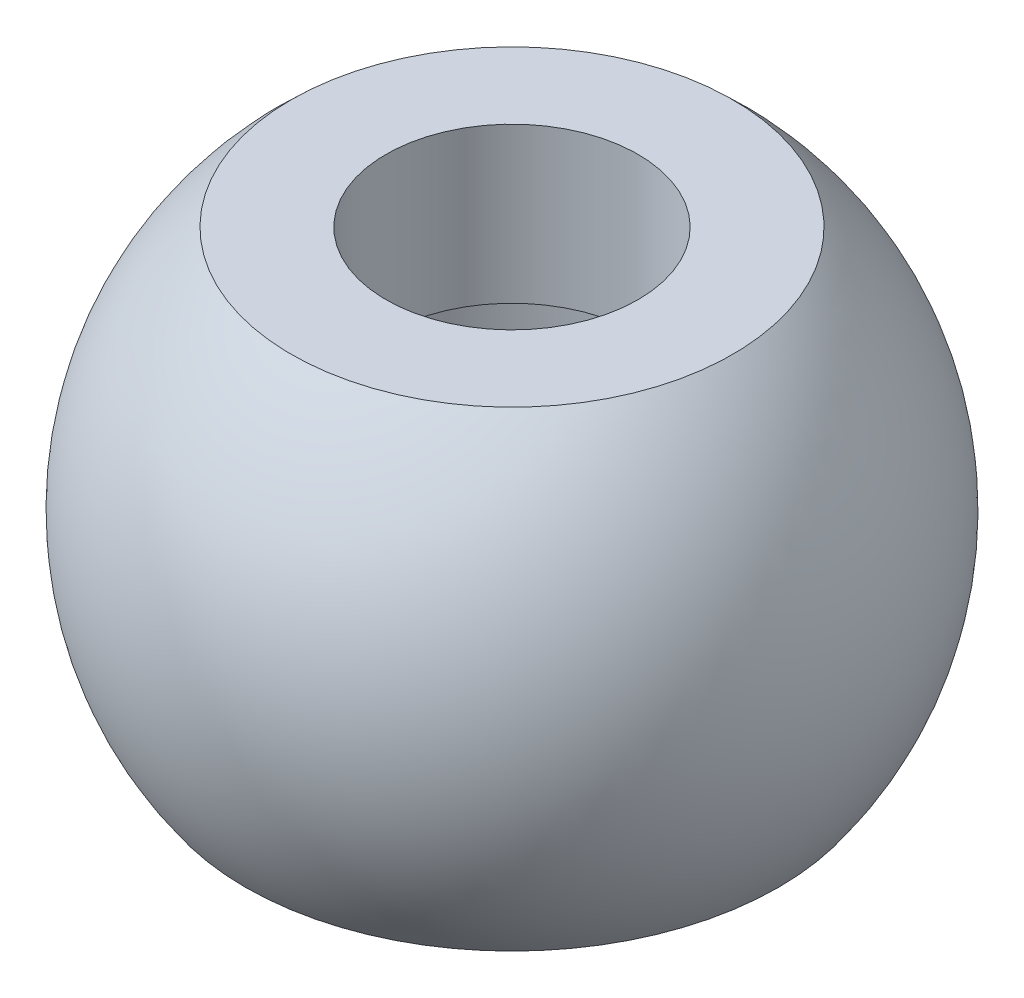
from build123d import *

# Parameters (mm, degrees)
SKETCH3_R           = 11.43
SKETCH3_R_2         = 8.255
BOSS_EXTRUDE3_DEPTH = 2.54


with BuildPart() as part:
    # Sketch1 → Revolve1 (revolve)
    with BuildSketch(Plane.XY, mode=Mode.PRIVATE) as revolve1_sk:
        with BuildLine():
            Line((-8.255, 16.035758426), (-14.45622882, 16.035758426))
            ThreePointArc((-14.45622882, 16.035758426), (-21.473034234, 2.244304079), (-17.459613398, -12.7))
            Line((-17.459613398, -12.7), (-11.43, -12.7))
            Line((-11.43, -12.7), (-11.43, 8.415758426))
            Line((-11.43, 8.415758426), (-8.255, 8.415758426))
            Line((-8.255, 8.415758426), (-8.255, 16.035758426))
        make_face()
    revolve(revolve1_sk.sketch.rotate(Axis((0, 0, 0), (0, 1, 0)), 180), axis=Axis((0, 0, 0), (0, 1, 0)))

    # Sketch3 → Boss-Extrude3 (add)
    with BuildSketch(Plane.XZ.offset(-8.415758426)):
        Circle(SKETCH3_R)
        Circle(SKETCH3_R_2, mode=Mode.SUBTRACT)
    extrude(amount=BOSS_EXTRUDE3_DEPTH)


solid = part.part
